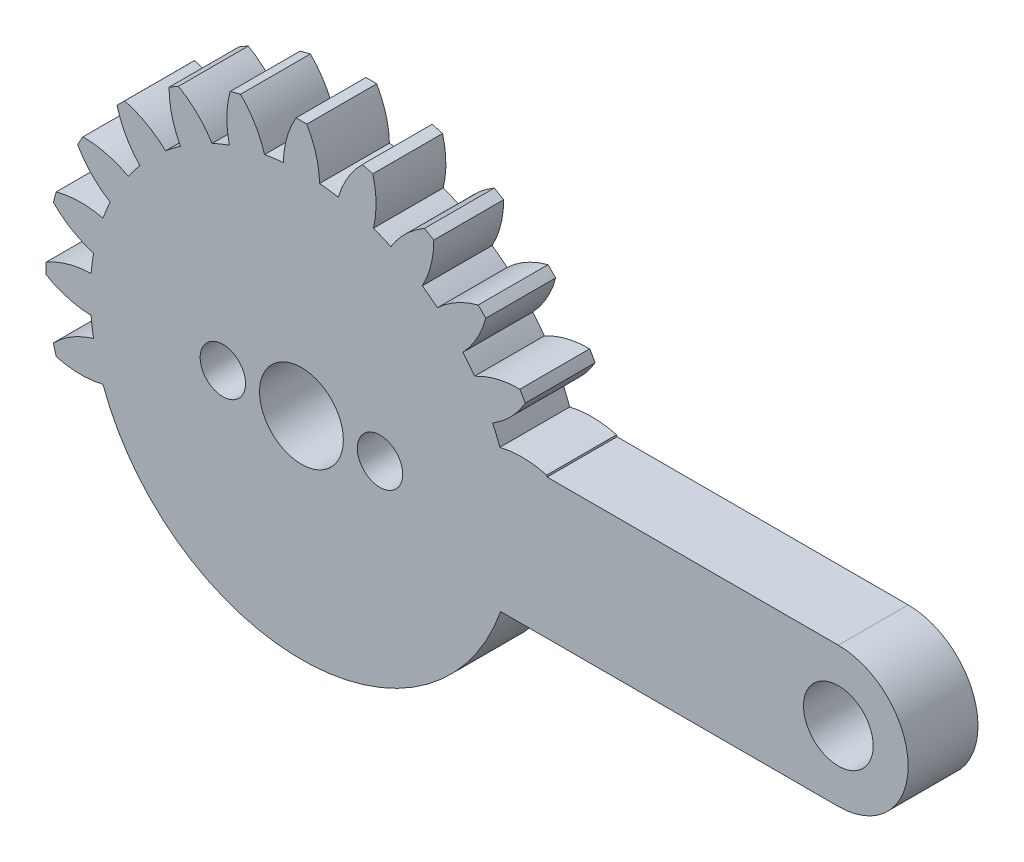
from build123d import *

# Parameters (mm, degrees)
SKETCH2_R           = 1.75
SKETCH2_R_2         = 1.995
BOSS_EXTRUDE1_DEPTH = 4
SKETCH4_R           = 1.3
SKETCH4_R_2         = 2.4
CUT_EXTRUDE1_DEPTH  = 5


with BuildPart() as part:
    # Sketch2 → Boss-Extrude1 (new body)
    with BuildSketch(Plane.XY):
        with BuildLine():
            ThreePointArc((30.75, -4), (34.75, 0), (30.75, 4))
            Line((30.75, 4), (14.072558403, 4))
            ThreePointArc((14.072558403, 4), (14.06038767, 4.04257326), (14.048088143, 4.085109489))
            ThreePointArc((14.048088143, 4.085109489), (12.709169027, 4.272836063), (11.365584201, 4.122086336))
            ThreePointArc((11.365584201, 4.122086336), (11.169703548, 4.626642697), (10.951436862, 5.12192646))
            ThreePointArc((10.951436862, 5.12192646), (12.008090957, 5.965388247), (12.82210701, 7.044889767))
            ThreePointArc((12.82210701, 7.044889767), (12.669951657, 7.315), (12.51210701, 7.581825517))
            ThreePointArc((12.51210701, 7.581825517), (11.170223244, 7.416617696), (9.911436862, 6.9232593))
            ThreePointArc((9.911436862, 6.9232593), (9.591641884, 7.359925677), (9.252623584, 7.781841479))
            ThreePointArc((9.252623584, 7.781841479), (10.05496909, 8.870045207), (10.561852666, 10.123446462))
            ThreePointArc((10.561852666, 10.123446462), (10.344972209, 10.344972209), (10.123446462, 10.561852666))
            ThreePointArc((10.123446462, 10.561852666), (8.870045207, 10.05496909), (7.781841479, 9.252623584))
            ThreePointArc((7.781841479, 9.252623584), (7.359925677, 9.591641884), (6.9232593, 9.911436862))
            ThreePointArc((6.9232593, 9.911436862), (7.416617696, 11.170223244), (7.581825517, 12.51210701))
            ThreePointArc((7.581825517, 12.51210701), (7.315, 12.669951657), (7.044889767, 12.82210701))
            ThreePointArc((7.044889767, 12.82210701), (5.965388247, 12.008090957), (5.12192646, 10.951436862))
            ThreePointArc((5.12192646, 10.951436862), (4.626642697, 11.169703548), (4.122086336, 11.365584201))
            ThreePointArc((4.122086336, 11.365584201), (4.272836063, 12.709169027), (4.085109489, 14.048088143))
            ThreePointArc((4.085109489, 14.048088143), (3.78652263, 14.131494839), (3.486235477, 14.208555951))
            ThreePointArc((3.486235477, 14.208555951), (2.654199937, 13.14288127), (2.112960617, 11.903927815))
            ThreePointArc((2.112960617, 11.903927815), (1.578061664, 11.986568374), (1.04, 12.04518576))
            ThreePointArc((1.04, 12.04518576), (0.837867713, 13.382005944), (0.31, 14.626715284))
            ThreePointArc((0.31, 14.626715284), (0, 14.63), (-0.31, 14.626715284))
            ThreePointArc((-0.31, 14.626715284), (-0.837867713, 13.382005944), (-1.04, 12.04518576))
            ThreePointArc((-1.04, 12.04518576), (-1.578061664, 11.986568374), (-2.112960617, 11.903927815))
            ThreePointArc((-2.112960617, 11.903927815), (-2.654199937, 13.14288127), (-3.486235477, 14.208555951))
            ThreePointArc((-3.486235477, 14.208555951), (-3.78652263, 14.131494839), (-4.085109489, 14.048088143))
            ThreePointArc((-4.085109489, 14.048088143), (-4.272836063, 12.709169027), (-4.122086336, 11.365584201))
            ThreePointArc((-4.122086336, 11.365584201), (-4.626642697, 11.169703548), (-5.12192646, 10.951436862))
            ThreePointArc((-5.12192646, 10.951436862), (-5.965388247, 12.008090957), (-7.044889767, 12.82210701))
            ThreePointArc((-7.044889767, 12.82210701), (-7.315, 12.669951657), (-7.581825517, 12.51210701))
            ThreePointArc((-7.581825517, 12.51210701), (-7.416617696, 11.170223244), (-6.9232593, 9.911436862))
            ThreePointArc((-6.9232593, 9.911436862), (-7.359925677, 9.591641884), (-7.781841479, 9.252623584))
            ThreePointArc((-7.781841479, 9.252623584), (-8.870045207, 10.05496909), (-10.123446462, 10.561852666))
            ThreePointArc((-10.123446462, 10.561852666), (-10.344972209, 10.344972209), (-10.561852666, 10.123446462))
            ThreePointArc((-10.561852666, 10.123446462), (-10.05496909, 8.870045207), (-9.252623584, 7.781841479))
            ThreePointArc((-9.252623584, 7.781841479), (-9.591641884, 7.359925677), (-9.911436862, 6.9232593))
            ThreePointArc((-9.911436862, 6.9232593), (-11.170223244, 7.416617696), (-12.51210701, 7.581825517))
            ThreePointArc((-12.51210701, 7.581825517), (-12.669951657, 7.315), (-12.82210701, 7.044889767))
            ThreePointArc((-12.82210701, 7.044889767), (-12.008090957, 5.965388247), (-10.951436862, 5.12192646))
            ThreePointArc((-10.951436862, 5.12192646), (-11.169703548, 4.626642697), (-11.365584201, 4.122086336))
            ThreePointArc((-11.365584201, 4.122086336), (-12.709169027, 4.272836063), (-14.048088143, 4.085109489))
            ThreePointArc((-14.048088143, 4.085109489), (-14.131494839, 3.78652263), (-14.208555951, 3.486235477))
            ThreePointArc((-14.208555951, 3.486235477), (-13.14288127, 2.654199937), (-11.903927815, 2.112960617))
            ThreePointArc((-11.903927815, 2.112960617), (-11.986568374, 1.578061664), (-12.04518576, 1.04))
            ThreePointArc((-12.04518576, 1.04), (-13.382005944, 0.837867713), (-14.626715284, 0.31))
            ThreePointArc((-14.626715284, 0.31), (-14.63, 0), (-14.626715284, -0.31))
            ThreePointArc((-14.626715284, -0.31), (-13.382005944, -0.837867713), (-12.04518576, -1.04))
            ThreePointArc((-12.04518576, -1.04), (-11.986568374, -1.578061664), (-11.903927815, -2.112960617))
            ThreePointArc((-11.903927815, -2.112960617), (-13.14288127, -2.654199937), (-14.208555951, -3.486235477))
            ThreePointArc((-14.208555951, -3.486235477), (-14.131494839, -3.78652263), (-14.048088143, -4.085109489))
            ThreePointArc((-14.048088143, -4.085109489), (-12.709169027, -4.272836063), (-11.365584201, -4.122086336))
            ThreePointArc((-11.365584201, -4.122086336), (0.064808849, -12.089826294), (11.409123542, -4))
            Line((11.409123542, -4), (30.75, -4))
        make_face()
        Circle(SKETCH2_R, mode=Mode.SUBTRACT)
        with Locations((30.75, 0)):
            Circle(SKETCH2_R_2, mode=Mode.SUBTRACT)
    extrude(amount=BOSS_EXTRUDE1_DEPTH)

    # Sketch4 → Cut-Extrude1 (cut, through all)
    with BuildSketch(Plane.XY.offset(4)):
        with Locations((4.5, 0)):
            Circle(SKETCH4_R)
        with Locations((-4.5, 0)):
            Circle(SKETCH4_R)
        Circle(SKETCH4_R_2)
    extrude(amount=-CUT_EXTRUDE1_DEPTH, mode=Mode.SUBTRACT)


solid = part.part
